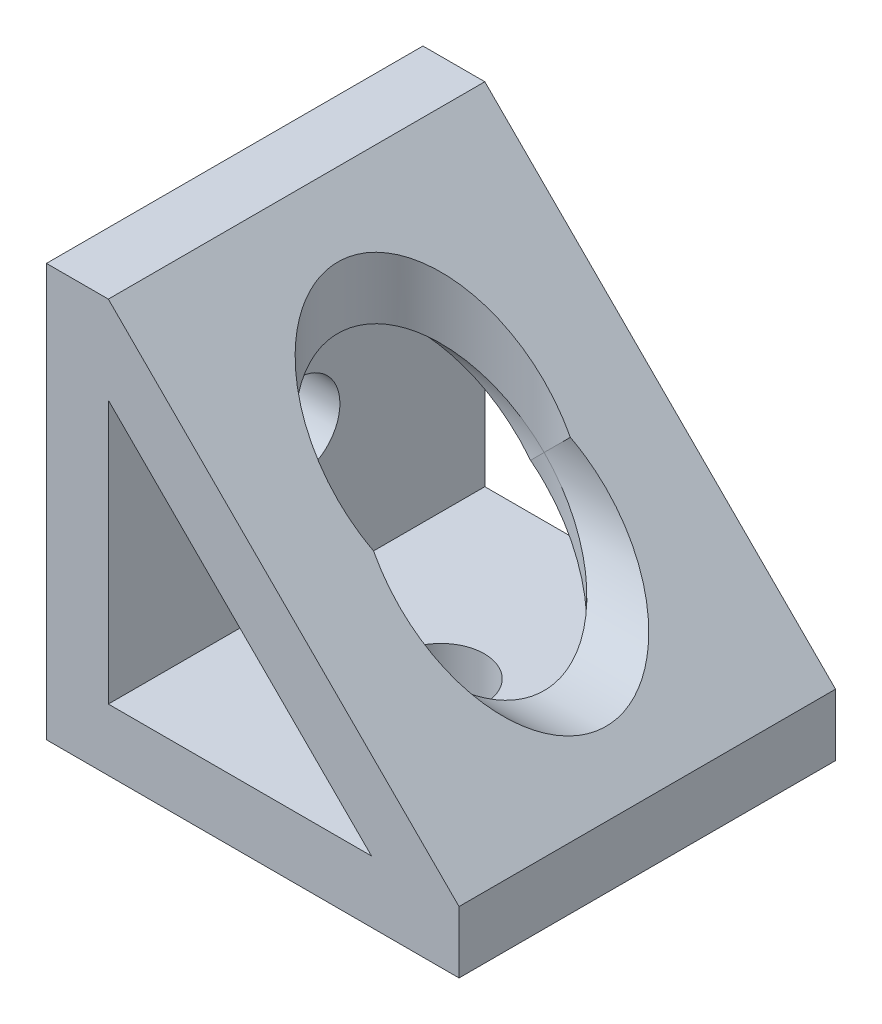
from build123d import *

# Parameters (mm, degrees)
BOSS_EXTRUDE1_DEPTH      = 18.25
BOSS_EXTRUDE1_DEPTH_BACK = 18.25
SKETCH4_R                = 4.2
CUT_EXTRUDE1_DEPTH       = 6
SKETCH6_R                = 10
CUT_EXTRUDE2_DEPTH       = 35


with BuildPart() as part:
    # Sketch2 → Boss-Extrude1 (new body, two sides)
    with BuildSketch(Plane.XY) as boss_extrude1_sk:
        Polygon((-20, 20), (-20, -20), (20, -20), (20, -14), (-14, 20), align=None)
        Polygon((-14, 11.514718626), (-14, -14), (11.514718626, -14), align=None, mode=Mode.SUBTRACT)
    extrude(amount=BOSS_EXTRUDE1_DEPTH)
    extrude(boss_extrude1_sk.sketch, amount=-BOSS_EXTRUDE1_DEPTH_BACK)

    # Sketch4 → Cut-Extrude1 (cut)
    with BuildSketch(Plane.XZ.offset(20)):
        Circle(SKETCH4_R)
    cut_extrude1 = extrude(amount=-CUT_EXTRUDE1_DEPTH, mode=Mode.SUBTRACT)

    # Sketch6 → Cut-Extrude2 (cut, through all)
    with BuildSketch(Plane(origin=(0, -14, 0), x_dir=(1, 0, 0), z_dir=(0, 1, 0))):
        Circle(SKETCH6_R)
    cut_extrude2 = extrude(amount=CUT_EXTRUDE2_DEPTH, mode=Mode.SUBTRACT)

    # Mirror1: Cut-Extrude1, Cut-Extrude2 across plane
    add(cut_extrude1.mirror(Plane(origin=(0, 0, 0), x_dir=(0, 0, 1), z_dir=(0.707106781, -0.707106781, 0))), mode=Mode.SUBTRACT)
    add(cut_extrude2.mirror(Plane(origin=(0, 0, 0), x_dir=(0, 0, 1), z_dir=(0.707106781, -0.707106781, 0))), mode=Mode.SUBTRACT)


solid = part.part
